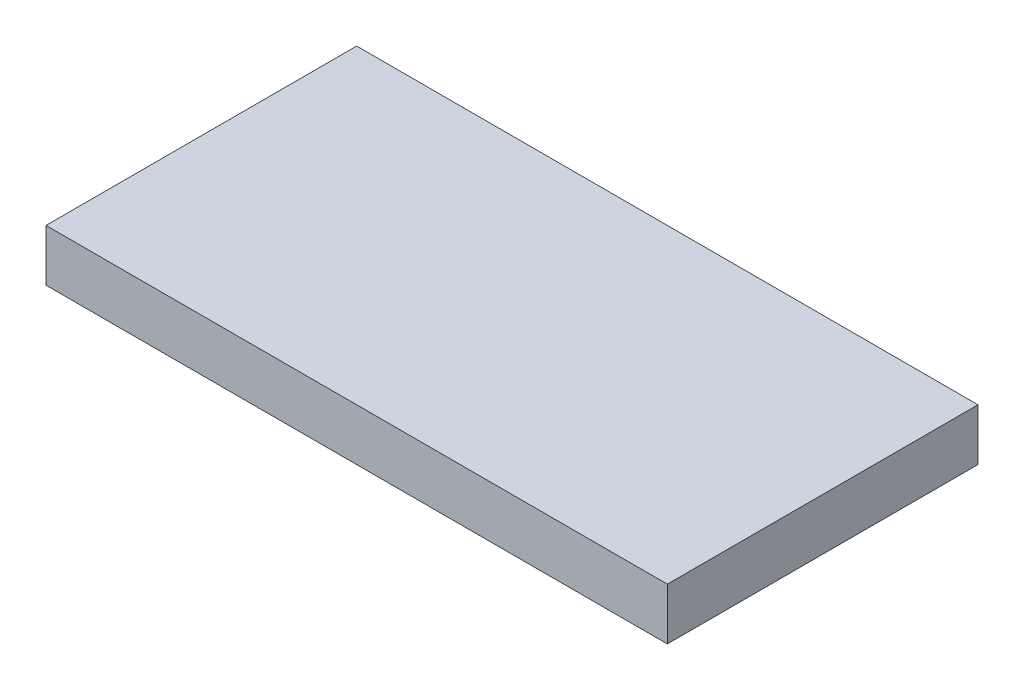
from build123d import *

# Parameters (mm, degrees)
SKETCH1_W           = 304.8
SKETCH1_H           = 152.4
BOSS_EXTRUDE1_DEPTH = 12.7


with BuildPart() as part:
    # Sketch1 → Boss-Extrude1 (new body, symmetric)
    with BuildSketch(Plane(origin=(0, 0, 0), x_dir=(1, 0, 0), z_dir=(0, 1, 0))):
        Rectangle(SKETCH1_W, SKETCH1_H)
    extrude(amount=BOSS_EXTRUDE1_DEPTH, both=True)


solid = part.part
